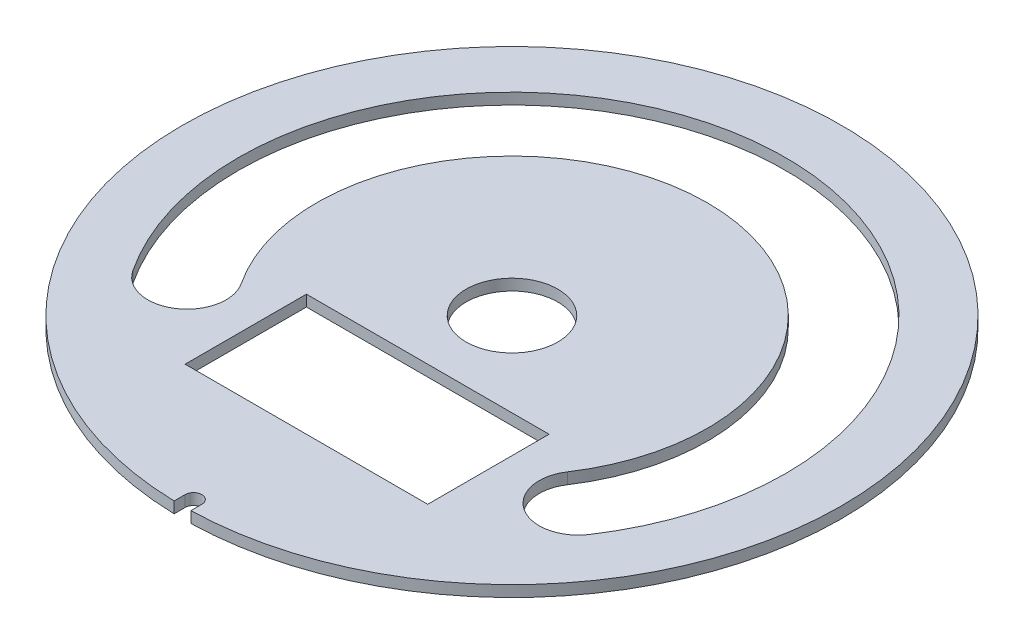
from build123d import *

# Parameters (mm, degrees)
SKETCH_1_R      = 4.1
SKETCH_1_W      = 21.7
SKETCH_1_H      = 10.85
EXTRUDE_1_DEPTH = 1


with BuildPart() as part:
    # Эскиз1 → Бобышка-Вытянуть1 (new body)
    with BuildSketch(Plane(origin=(0, 0, 0), x_dir=(1, 0, 0), z_dir=(0, 1, 0))):
        with BuildLine():
            Line((0.75, -28.503654365), (0.75, -29.46545647))
            ThreePointArc((0.75, -29.46545647), (0, 29.475), (-0.75, -29.46545647))
            Line((-0.75, -29.46545647), (-0.75, -28.503654365))
            ThreePointArc((-0.75, -28.503654365), (0, -27.732186207), (0.75, -28.503654365))
        make_face()
        Circle(SKETCH_1_R, mode=Mode.SUBTRACT)
        with Locations((0, -12.957484911)):
            Rectangle(SKETCH_1_W, SKETCH_1_H, mode=Mode.SUBTRACT)
        with BuildLine():
            ThreePointArc((20.420143027, -13.492345376), (0, 24.475), (-20.420143027, -13.492345376))
            ThreePointArc((-20.420143027, -13.492345376), (-15.570553266, -14.483041669), (-14.579856973, -9.633451908))
            ThreePointArc((-14.579856973, -9.633451908), (0, 17.475), (14.579856973, -9.633451908))
            ThreePointArc((14.579856973, -9.633451908), (15.570553266, -14.483041669), (20.420143027, -13.492345376))
        make_face(mode=Mode.SUBTRACT)
    extrude(amount=EXTRUDE_1_DEPTH)


solid = part.part
